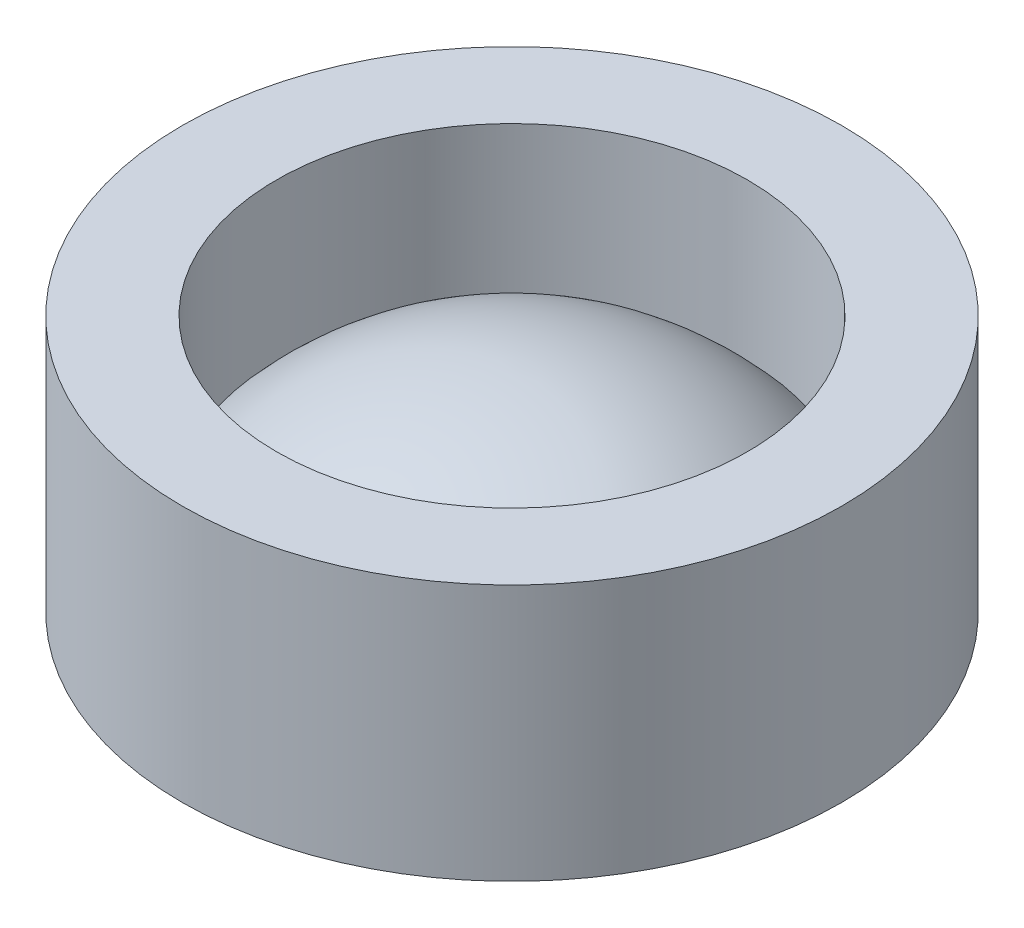
from build123d import *

# Parameters (mm, degrees)
SKETCH1_R           = 10.5
BOSS_EXTRUDE1_DEPTH = 8.17408016


with BuildPart() as part:
    # Sketch1 → Boss-Extrude1 (new body)
    with BuildSketch(Plane(origin=(0, 0, 0), x_dir=(1, 0, 0), z_dir=(0, 1, 0))):
        Circle(SKETCH1_R)
    extrude(amount=BOSS_EXTRUDE1_DEPTH)

    # Sketch2 → Cut-Revolve2 (revolve, cut)
    with BuildSketch(Plane(origin=(0, 0, 0), x_dir=(0, 0, -1), z_dir=(1, 0, 0))):
        with BuildLine():
            Line((0, 8.17408016), (7.5, 8.17408016))
            Line((7.5, 8.17408016), (7.5, 3.17408016))
            ThreePointArc((7.5, 3.17408016), (4.114378278, 5.67408016), (0, 6.559701883))
            Line((0, 6.559701883), (0, 8.17408016))
        make_face()
    revolve(axis=Axis((0, 0.049098768, 0), (0, 1, 0)), mode=Mode.SUBTRACT)


solid = part.part
